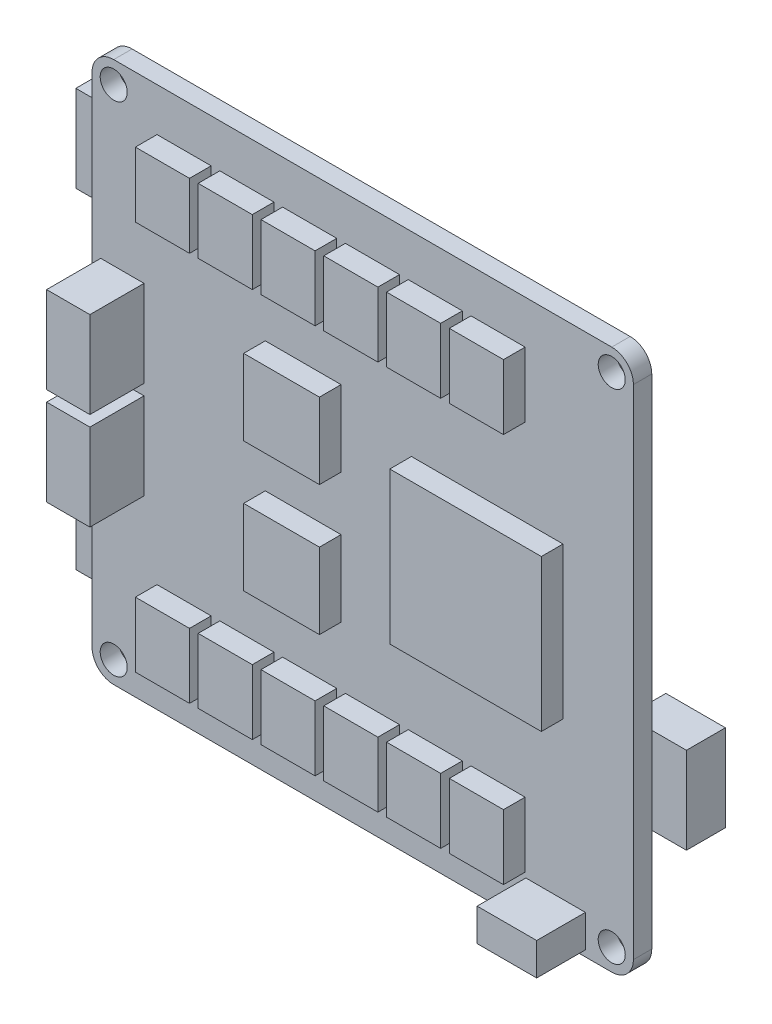
from build123d import *

# Parameters (mm, degrees)
SKIZZE1_W                       = 50
SKIZZE1_H                       = 50
SKIZZE1_R                       = 1.25
AUFSATZ_LINEAR_AUSTRAGEN1_DEPTH = 1.7
VERRUNDUNG1_R                   = 2
SKIZZE2_W                       = 14
SKIZZE2_H                       = 14
SKIZZE2_W_2                     = 7
SKIZZE2_H_2                     = 7
SKIZZE2_W_3                     = 5
SKIZZE2_H_3                     = 6
AUFSATZ_LINEAR_AUSTRAGEN2_DEPTH = 2
SKIZZE3_W                       = 4
SKIZZE3_H                       = 8
AUFSATZ_LINEAR_AUSTRAGEN3_DEPTH = 5
SKIZZE5_W                       = 5.5
SKIZZE5_H                       = 3
AUFSATZ_LINEAR_AUSTRAGEN5_DEPTH = 4.5
SKIZZE6_W                       = 5.5
SKIZZE6_H                       = 8
AUFSATZ_LINEAR_AUSTRAGEN6_DEPTH = 3.6


with BuildPart() as part:
    # Skizze1 → Aufsatz-Linear austragen1 (new body)
    with BuildSketch(Plane.XY):
        Rectangle(SKIZZE1_W, SKIZZE1_H)
        with Locations((-23, 23)):
            Circle(SKIZZE1_R, mode=Mode.SUBTRACT)
        with Locations((23, 23)):
            Circle(SKIZZE1_R, mode=Mode.SUBTRACT)
        with Locations((23, -23)):
            Circle(SKIZZE1_R, mode=Mode.SUBTRACT)
        with Locations((-23, -23)):
            Circle(SKIZZE1_R, mode=Mode.SUBTRACT)
    extrude(amount=AUFSATZ_LINEAR_AUSTRAGEN1_DEPTH)

    # Verrundung1
    verrundung1_edges = [part.edges().sort_by_distance(p)[0] for p in [
        (25, 25, 0.85),
        (25, -25, 0.85),
        (-25, -25, 0.85),
        (-25, 25, 0.85),
    ]]
    fillet(verrundung1_edges, radius=VERRUNDUNG1_R)

    # Skizze2 → Aufsatz-Linear austragen2 (add)
    with BuildSketch(Plane.XY.offset(1.7)):
        with Locations((11.5, 0)):
            Rectangle(SKIZZE2_W, SKIZZE2_H)
        with Locations((-5.5, 6)):
            Rectangle(SKIZZE2_W_2, SKIZZE2_H_2)
        with Locations((-5.5, -6)):
            Rectangle(SKIZZE2_W_2, SKIZZE2_H_2)
        with Locations((-10.7, 18)):
            Rectangle(SKIZZE2_W_3, SKIZZE2_H_3)
        with Locations((-16.5, 18)):
            Rectangle(SKIZZE2_W_3, SKIZZE2_H_3)
        with Locations((-4.9, 18)):
            Rectangle(SKIZZE2_W_3, SKIZZE2_H_3)
        with Locations((0.9, 18)):
            Rectangle(SKIZZE2_W_3, SKIZZE2_H_3)
        with Locations((6.7, 18)):
            Rectangle(SKIZZE2_W_3, SKIZZE2_H_3)
        with Locations((12.5, 18)):
            Rectangle(SKIZZE2_W_3, SKIZZE2_H_3)
        with Locations((12.5, -18)):
            Rectangle(SKIZZE2_W_3, SKIZZE2_H_3)
        with Locations((6.7, -18)):
            Rectangle(SKIZZE2_W_3, SKIZZE2_H_3)
        with Locations((0.9, -18)):
            Rectangle(SKIZZE2_W_3, SKIZZE2_H_3)
        with Locations((-4.9, -18)):
            Rectangle(SKIZZE2_W_3, SKIZZE2_H_3)
        with Locations((-10.7, -18)):
            Rectangle(SKIZZE2_W_3, SKIZZE2_H_3)
        with Locations((-16.5, -18)):
            Rectangle(SKIZZE2_W_3, SKIZZE2_H_3)
    extrude(amount=AUFSATZ_LINEAR_AUSTRAGEN2_DEPTH)

    # Skizze3 → Aufsatz-Linear austragen3 (add)
    with BuildSketch(Plane.XY.offset(1.7)):
        with Locations((-22.2, -4.5)):
            Rectangle(SKIZZE3_W, SKIZZE3_H)
        with Locations((-22.2, 4.5)):
            Rectangle(SKIZZE3_W, SKIZZE3_H)
    extrude(amount=AUFSATZ_LINEAR_AUSTRAGEN3_DEPTH)

    # Skizze5 → Aufsatz-Linear austragen5 (add)
    with BuildSketch(Plane.XY.offset(1.7)):
        with Locations((17.817192877, -22.933750346)):
            Rectangle(SKIZZE5_W, SKIZZE5_H)
    extrude(amount=AUFSATZ_LINEAR_AUSTRAGEN5_DEPTH)

    # Skizze6 → Aufsatz-Linear austragen6 (add)
    with BuildSketch(Plane(origin=(0, 0, 0), x_dir=(-1, 0, 0), z_dir=(0, 0, -1))):
        with Locations((25.45, 15.25)):
            Rectangle(SKIZZE6_W, SKIZZE6_H)
        with Locations((25.45, -15.25)):
            Rectangle(SKIZZE6_W, SKIZZE6_H)
        with Locations((-25.45, -9.5)):
            Rectangle(SKIZZE6_W, SKIZZE6_H)
    extrude(amount=AUFSATZ_LINEAR_AUSTRAGEN6_DEPTH)


solid = part.part
